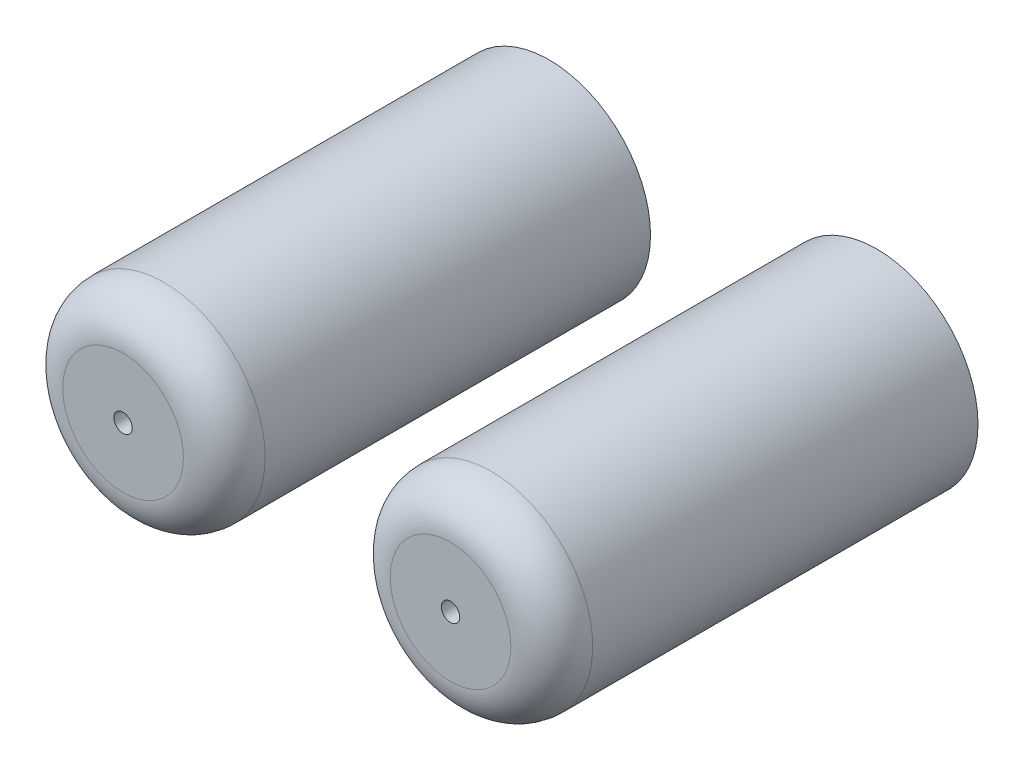
from build123d import *

# Parameters (mm, degrees)
ESQUISSE1_R             = 12.375
BOSS_EXTRU_1_DEPTH      = 52.11
BOSS_EXTRU_1_2_DEPTH    = 52.11
CONG_1_R                = 5
CONG_2_R                = 5
ESQUISSE2_R             = 1.125
ENL_V_MAT_EXTRU_1_DEPTH = 52.11
ESQUISSE3_R             = 1.5
ENL_V_MAT_EXTRU_2_DEPTH = 20
CONG_3_R                = 0.25
CONG_4_R                = 0.25
CONG_5_R                = 0.25
CONG_6_R                = 0.25


with BuildPart() as part:
    # Esquisse1 → Boss.-Extru.1 (new body)
    with BuildSketch(Plane.XY):
        Circle(ESQUISSE1_R)
    extrude(amount=BOSS_EXTRU_1_DEPTH)

    # Congé2
    cong_2_edges = [part.edges().sort_by_distance(p)[0] for p in [
        (-12.375, 0, 52.11),
    ]]
    fillet(cong_2_edges, radius=CONG_2_R)


with BuildPart() as body_2:
    # Esquisse1 → Boss.-Extru.1 2 (new body)
    with BuildSketch(Plane.XY):
        with Locations((40.04, 0)):
            Circle(ESQUISSE1_R)
    extrude(amount=BOSS_EXTRU_1_2_DEPTH)

    # Congé1
    cong_1_edges = [body_2.edges().sort_by_distance(p)[0] for p in [
        (27.665, 0, 52.11),
    ]]
    fillet(cong_1_edges, radius=CONG_1_R)


with BuildPart() as enl_v_mat_extru_1_tool:
    # Esquisse2 → Enlèv. mat.-Extru.1 (new body)
    with BuildSketch(Plane.XY.offset(52.11)):
        Circle(ESQUISSE2_R)
        with Locations((40.04, 0)):
            Circle(ESQUISSE2_R)
    extrude(amount=-ENL_V_MAT_EXTRU_1_DEPTH)


with BuildPart() as part_1:
    add(part.part)

    # Enlèv. mat.-Extru.1: cut by enl_v_mat_extru_1_tool
    add(enl_v_mat_extru_1_tool.part, mode=Mode.SUBTRACT)


with BuildPart() as body_2_1:
    add(body_2.part)

    # Enlèv. mat.-Extru.1: cut by enl_v_mat_extru_1_tool
    add(enl_v_mat_extru_1_tool.part, mode=Mode.SUBTRACT)


with BuildPart() as enl_v_mat_extru_2_tool:
    # Esquisse3 → Enlèv. mat.-Extru.2 (new body)
    with BuildSketch(Plane(origin=(0, 0, 0), x_dir=(-1, 0, 0), z_dir=(0, 0, -1))):
        Circle(ESQUISSE3_R)
        with Locations((-40.04, 0)):
            Circle(ESQUISSE3_R)
    extrude(amount=-ENL_V_MAT_EXTRU_2_DEPTH)


with BuildPart() as part_2:
    add(part_1.part)

    # Enlèv. mat.-Extru.2: cut by enl_v_mat_extru_2_tool
    add(enl_v_mat_extru_2_tool.part, mode=Mode.SUBTRACT)

    # Congé5
    cong_5_edges = [part_2.edges().sort_by_distance(p)[0] for p in [
        (-1.125, 0, 20),
    ]]
    fillet(cong_5_edges, radius=CONG_5_R)

    # Congé6
    cong_6_edges = [part_2.edges().sort_by_distance(p)[0] for p in [
        (1.5, 0, 20),
    ]]
    fillet(cong_6_edges, radius=CONG_6_R)


with BuildPart() as body_2_2:
    add(body_2_1.part)

    # Enlèv. mat.-Extru.2: cut by enl_v_mat_extru_2_tool
    add(enl_v_mat_extru_2_tool.part, mode=Mode.SUBTRACT)

    # Congé3
    cong_3_edges = [body_2_2.edges().sort_by_distance(p)[0] for p in [
        (41.54, 0, 20),
    ]]
    fillet(cong_3_edges, radius=CONG_3_R)

    # Congé4
    cong_4_edges = [body_2_2.edges().sort_by_distance(p)[0] for p in [
        (38.915, 0, 20),
    ]]
    fillet(cong_4_edges, radius=CONG_4_R)


solid = Compound([part_2.part, body_2_2.part])
